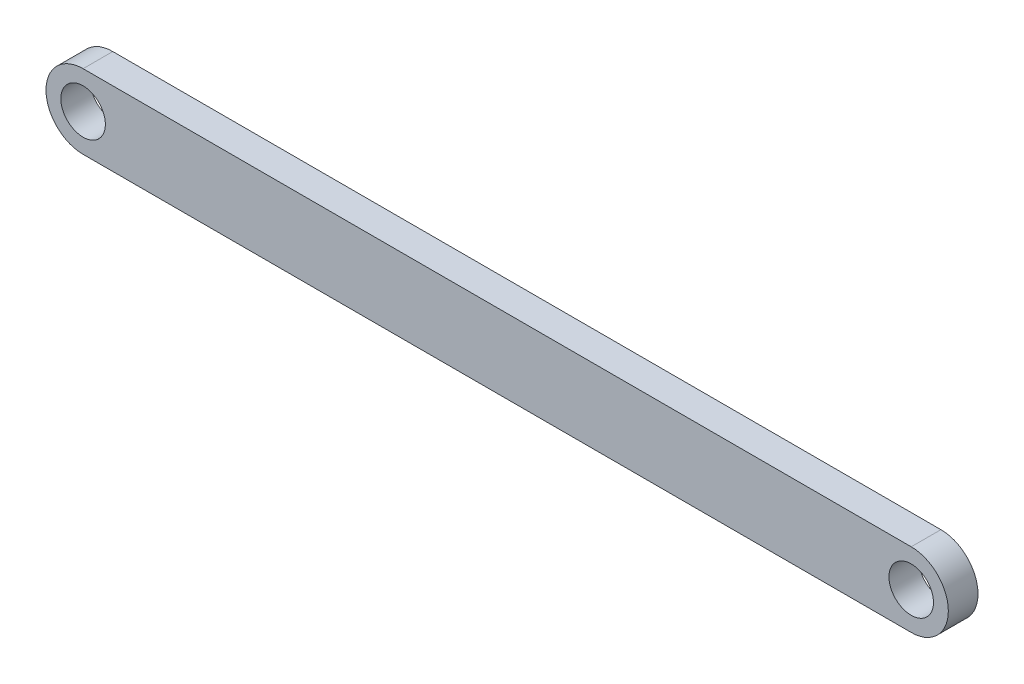
from build123d import *

# Parameters (mm, degrees)
SKETCH1_R           = 1.5
BOSS_EXTRUDE1_DEPTH = 2


with BuildPart() as part:
    # Sketch1 → Boss-Extrude1 (new body)
    with BuildSketch(Plane.XY):
        with BuildLine():
            Line((0.058624922, 2.519383592), (55.858624922, 2.519383592))
            ThreePointArc((55.858624922, 2.519383592), (58.358624922, 0.019383592), (55.858624922, -2.480616408))
            Line((55.858624922, -2.480616408), (0.058624922, -2.480616408))
            ThreePointArc((0.058624922, -2.480616408), (-2.441375078, 0.019383592), (0.058624922, 2.519383592))
        make_face()
        with Locations((0.058624922, 0.019383592)):
            Circle(SKETCH1_R, mode=Mode.SUBTRACT)
        with Locations((55.858624922, 0.019383592)):
            Circle(SKETCH1_R, mode=Mode.SUBTRACT)
    extrude(amount=BOSS_EXTRUDE1_DEPTH)


solid = part.part
